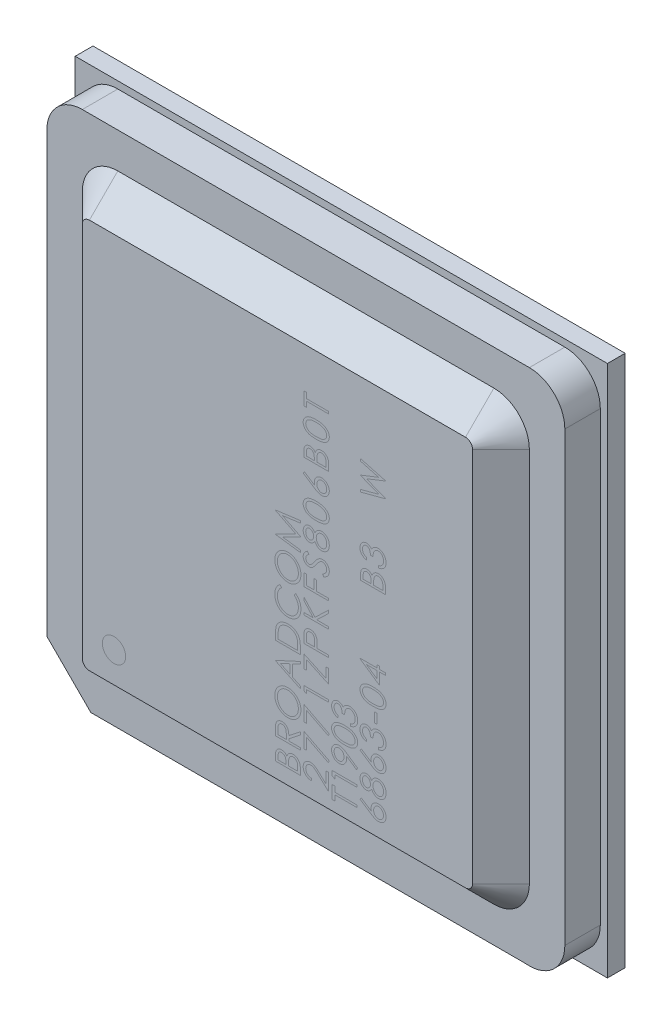
from build123d import *

# Parameters (mm, degrees)
SKETCH2_W           = 15
SKETCH2_H           = 15
BOSS_EXTRUDE1_DEPTH = 0.5
BOSS_EXTRUDE2_DEPTH = 1
SKETCH4_R           = 0.2
CUT_EXTRUDE1_DEPTH  = 0.1
BOSS_EXTRUDE3_DEPTH = 0.8
BOSS_EXTRUDE3_TAPER = 45


with BuildPart() as part:
    # Sketch2 → Boss-Extrude1 (new body)
    with BuildSketch(Plane.XY):
        Rectangle(SKETCH2_W, SKETCH2_H)
    extrude(amount=BOSS_EXTRUDE1_DEPTH)

    # Sketch3 → Boss-Extrude2 (add)
    with BuildSketch(Plane.XY.offset(0.5)):
        with BuildLine():
            Line((7.3, -6.306243621), (7.3, 6.3))
            ThreePointArc((7.3, 6.3), (7.007106781, 7.007106781), (6.3, 7.3))
            Line((6.3, 7.3), (-6.3, 7.3))
            ThreePointArc((-6.3, 7.3), (-7.007106781, 7.007106781), (-7.3, 6.3))
            Line((-7.3, 6.3), (-7.3, -6.06))
            Line((-7.3, -6.06), (-6.06, -7.3))
            Line((-6.06, -7.3), (6.188428235, -7.3))
            ThreePointArc((6.188428235, -7.3), (6.966493899, -7.051754105), (7.3, -6.306243621))
        make_face()
    extrude(amount=BOSS_EXTRUDE2_DEPTH)

    # Sketch4 → Cut-Extrude1 (cut)
    with BuildSketch(Plane.XY.offset(0.5)):
        with Locations((-7.013506318, -7.013506318)):
            Circle(SKETCH4_R)
    extrude(amount=-CUT_EXTRUDE1_DEPTH, mode=Mode.SUBTRACT)

    # Sketch5 → Boss-Extrude3 (add)
    with BuildSketch(Plane.XY.offset(1.5)):
        with BuildLine():
            Line((-5.3, -6.3), (5.3, -6.3))
            ThreePointArc((5.3, -6.3), (6.007106781, -6.007106781), (6.3, -5.3))
            Line((6.3, -5.3), (6.3, 5.3))
            ThreePointArc((6.3, 5.3), (6.007106781, 6.007106781), (5.3, 6.3))
            Line((5.3, 6.3), (-5.3, 6.3))
            ThreePointArc((-5.3, 6.3), (-6.007106781, 6.007106781), (-6.3, 5.3))
            Line((-6.3, 5.3), (-6.3, -5.3))
            ThreePointArc((-6.3, -5.3), (-6.007106781, -6.007106781), (-5.3, -6.3))
        make_face()
    extrude(amount=BOSS_EXTRUDE3_DEPTH, taper=BOSS_EXTRUDE3_TAPER)


solid = part.part
